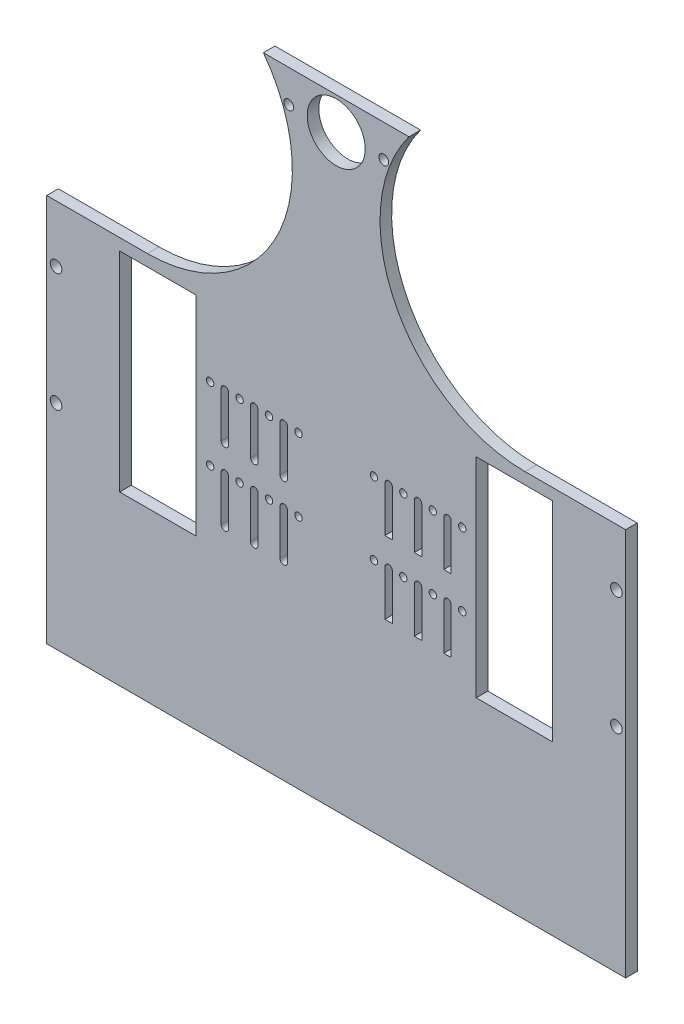
from build123d import *

# Parameters (mm, degrees)
SKETCH1_W           = 249.6
SKETCH1_H           = 350.4
SKETCH1_R           = 2.1
SKETCH1_R_2         = 2.5
SKETCH1_R_3         = 1.59
SKETCH1_R_4         = 12.5
SKETCH1_W_2         = 33
SKETCH1_H_2         = 90
BOSS_EXTRUDE1_DEPTH = 5
SKETCH12_W          = 249.6
SKETCH12_H          = 5
CUT_EXTRUDE2_DEPTH  = 83
CUT_EXTRUDE3_DEPTH  = 6


with BuildPart() as part:
    # Sketch1 → Boss-Extrude1 (new body)
    with BuildSketch(Plane.XY):
        with Locations((124.8, -175.2)):
            Rectangle(SKETCH1_W, SKETCH1_H)
        with Locations((104.3, -14)):
            Circle(SKETCH1_R, mode=Mode.SUBTRACT)
        with Locations((245.6, -124.5)):
            Circle(SKETCH1_R_2, mode=Mode.SUBTRACT)
        with Locations((245.6, -175.5)):
            Circle(SKETCH1_R_2, mode=Mode.SUBTRACT)
        with Locations((145.3, -14)):
            Circle(SKETCH1_R, mode=Mode.SUBTRACT)
        with Locations((179.16, -134.375)):
            Circle(SKETCH1_R_3, mode=Mode.SUBTRACT)
        with Locations((179.16, -165.625)):
            Circle(SKETCH1_R_3, mode=Mode.SUBTRACT)
        with Locations((124.8, -14)):
            Circle(SKETCH1_R_4, mode=Mode.SUBTRACT)
        with Locations((141.06, -134.375)):
            Circle(SKETCH1_R_3, mode=Mode.SUBTRACT)
        with Locations((153.76, -134.375)):
            Circle(SKETCH1_R_3, mode=Mode.SUBTRACT)
        with Locations((166.46, -134.375)):
            Circle(SKETCH1_R_3, mode=Mode.SUBTRACT)
        with Locations((141.06, -165.625)):
            Circle(SKETCH1_R_3, mode=Mode.SUBTRACT)
        with Locations((153.76, -165.625)):
            Circle(SKETCH1_R_3, mode=Mode.SUBTRACT)
        with Locations((166.46, -165.625)):
            Circle(SKETCH1_R_3, mode=Mode.SUBTRACT)
        with Locations((83.14, -165.625)):
            Circle(SKETCH1_R_3, mode=Mode.SUBTRACT)
        with Locations((95.84, -165.625)):
            Circle(SKETCH1_R_3, mode=Mode.SUBTRACT)
        with Locations((108.54, -165.625)):
            Circle(SKETCH1_R_3, mode=Mode.SUBTRACT)
        with Locations((83.14, -134.375)):
            Circle(SKETCH1_R_3, mode=Mode.SUBTRACT)
        with Locations((95.84, -134.375)):
            Circle(SKETCH1_R_3, mode=Mode.SUBTRACT)
        with Locations((108.54, -134.375)):
            Circle(SKETCH1_R_3, mode=Mode.SUBTRACT)
        with Locations((70.44, -165.625)):
            Circle(SKETCH1_R_3, mode=Mode.SUBTRACT)
        with Locations((70.44, -134.375)):
            Circle(SKETCH1_R_3, mode=Mode.SUBTRACT)
        with Locations((4, -175.5)):
            Circle(SKETCH1_R_2, mode=Mode.SUBTRACT)
        with Locations((4, -124.5)):
            Circle(SKETCH1_R_2, mode=Mode.SUBTRACT)
        with Locations((201.66, -150)):
            Rectangle(SKETCH1_W_2, SKETCH1_H_2, mode=Mode.SUBTRACT)
        with BuildLine():
            Line((145.8225, -134.375), (145.8225, -154.054634918))
            ThreePointArc((145.8225, -154.054634918), (147.41, -154.140223925), (148.9975, -154.054634918))
            Line((148.9975, -154.054634918), (148.9975, -134.375))
            ThreePointArc((148.9975, -134.375), (147.41, -132.7875), (145.8225, -134.375))
        make_face(mode=Mode.SUBTRACT)
        with BuildLine():
            Line((158.52, -134.375), (158.52, -154.054634918))
            ThreePointArc((158.52, -154.054634918), (160.11, -154.140492925), (161.7, -154.054634918))
            Line((161.7, -154.054634918), (161.7, -134.375))
            ThreePointArc((161.7, -134.375), (160.11, -132.785), (158.52, -134.375))
        make_face(mode=Mode.SUBTRACT)
        with BuildLine():
            Line((171.22, -134.375), (171.22, -154.054634918))
            ThreePointArc((171.22, -154.054634918), (172.81, -154.140492925), (174.4, -154.054634918))
            Line((174.4, -154.054634918), (174.4, -134.375))
            ThreePointArc((174.4, -134.375), (172.81, -132.785), (171.22, -134.375))
        make_face(mode=Mode.SUBTRACT)
        with BuildLine():
            Line((145.8225, -165.625), (145.8225, -185.304634918))
            ThreePointArc((145.8225, -185.304634918), (147.41, -185.390223925), (148.9975, -185.304634918))
            Line((148.9975, -185.304634918), (148.9975, -165.625))
            ThreePointArc((148.9975, -165.625), (147.41, -164.0375), (145.8225, -165.625))
        make_face(mode=Mode.SUBTRACT)
        with BuildLine():
            Line((158.52, -165.625), (158.52, -185.304634918))
            ThreePointArc((158.52, -185.304634918), (160.11, -185.390492925), (161.7, -185.304634918))
            Line((161.7, -185.304634918), (161.7, -165.625))
            ThreePointArc((161.7, -165.625), (160.11, -164.035), (158.52, -165.625))
        make_face(mode=Mode.SUBTRACT)
        with BuildLine():
            Line((171.22, -165.625), (171.22, -185.304634918))
            ThreePointArc((171.22, -185.304634918), (172.81, -185.390492925), (174.4, -185.304634918))
            Line((174.4, -185.304634918), (174.4, -165.625))
            ThreePointArc((174.4, -165.625), (172.81, -164.035), (171.22, -165.625))
        make_face(mode=Mode.SUBTRACT)
        with BuildLine():
            Line((103.7775, -134.375), (103.7775, -154.054634918))
            ThreePointArc((103.7775, -154.054634918), (102.19, -155.642134918), (100.6025, -154.054634918))
            Line((100.6025, -154.054634918), (100.6025, -134.375))
            ThreePointArc((100.6025, -134.375), (102.19, -132.7875), (103.7775, -134.375))
        make_face(mode=Mode.SUBTRACT)
        with BuildLine():
            Line((91.08, -134.375), (91.08, -154.054634918))
            ThreePointArc((91.08, -154.054634918), (89.49, -155.644634918), (87.9, -154.054634918))
            Line((87.9, -154.054634918), (87.9, -134.375))
            ThreePointArc((87.9, -134.375), (89.49, -132.785), (91.08, -134.375))
        make_face(mode=Mode.SUBTRACT)
        with BuildLine():
            Line((78.38, -134.375), (78.38, -154.054634918))
            ThreePointArc((78.38, -154.054634918), (76.79, -155.644634918), (75.2, -154.054634918))
            Line((75.2, -154.054634918), (75.2, -134.375))
            ThreePointArc((75.2, -134.375), (76.79, -132.785), (78.38, -134.375))
        make_face(mode=Mode.SUBTRACT)
        with BuildLine():
            Line((103.7775, -165.625), (103.7775, -185.304634918))
            ThreePointArc((103.7775, -185.304634918), (102.19, -186.892134918), (100.6025, -185.304634918))
            Line((100.6025, -185.304634918), (100.6025, -165.625))
            ThreePointArc((100.6025, -165.625), (102.19, -164.0375), (103.7775, -165.625))
        make_face(mode=Mode.SUBTRACT)
        with BuildLine():
            Line((91.08, -165.625), (91.08, -185.304634918))
            ThreePointArc((91.08, -185.304634918), (89.49, -186.894634918), (87.9, -185.304634918))
            Line((87.9, -185.304634918), (87.9, -165.625))
            ThreePointArc((87.9, -165.625), (89.49, -164.035), (91.08, -165.625))
        make_face(mode=Mode.SUBTRACT)
        with BuildLine():
            Line((78.38, -165.625), (78.38, -185.304634918))
            ThreePointArc((78.38, -185.304634918), (76.79, -186.894634918), (75.2, -185.304634918))
            Line((75.2, -185.304634918), (75.2, -165.625))
            ThreePointArc((75.2, -165.625), (76.79, -164.035), (78.38, -165.625))
        make_face(mode=Mode.SUBTRACT)
        with Locations((47.94, -150)):
            Rectangle(SKETCH1_W_2, SKETCH1_H_2, mode=Mode.SUBTRACT)
    extrude(amount=BOSS_EXTRUDE1_DEPTH)

    # Sketch12 → Cut-Extrude2 (cut)
    with BuildSketch(Plane.XZ.offset(350.4)):
        with Locations((124.8, 2.5)):
            Rectangle(SKETCH12_W, SKETCH12_H)
    extrude(amount=-CUT_EXTRUDE2_DEPTH, mode=Mode.SUBTRACT)

    # Sketch13 → Cut-Extrude3 (cut, through all)
    with BuildSketch(Plane.XY.offset(5)):
        with BuildLine():
            Line((43.402860001, -100), (0, -100))
            Line((0, -100), (0, 25))
            Line((0, 25), (43.402860001, 25))
            ThreePointArc((43.402860001, 25), (105.902860001, -37.5), (43.402860001, -100))
        make_face()
        with BuildLine():
            Line((206.197139999, 25), (249.6, 25))
            Line((249.6, 25), (249.6, -100))
            Line((249.6, -100), (206.197139999, -100))
            ThreePointArc((206.197139999, -100), (143.697139999, -37.5), (206.197139999, 25))
        make_face()
    extrude(amount=-CUT_EXTRUDE3_DEPTH, mode=Mode.SUBTRACT)


solid = part.part
